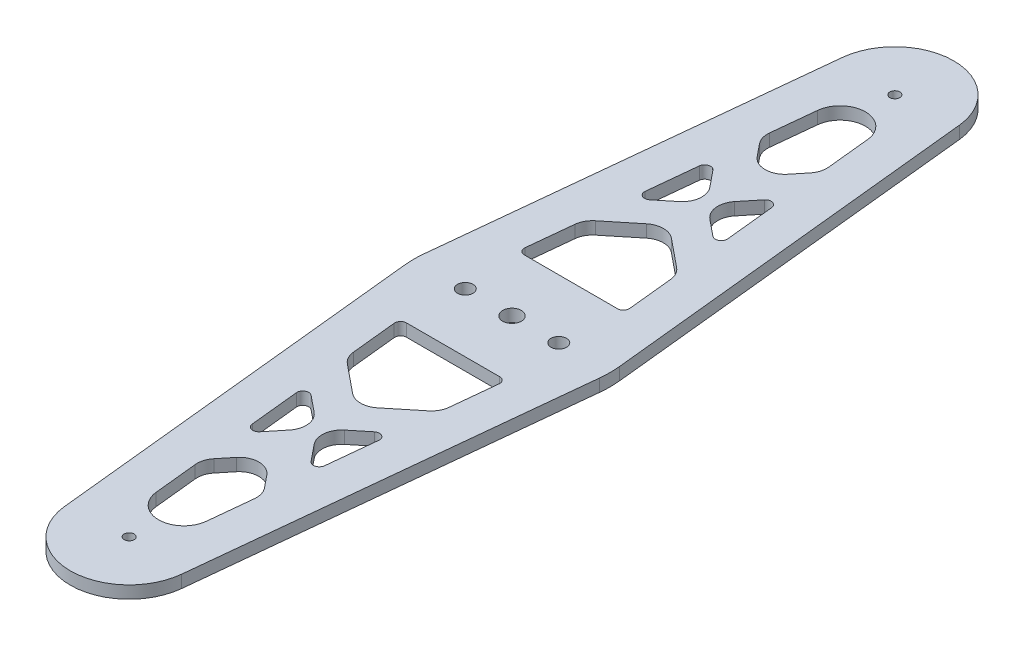
from build123d import *

# Parameters (mm, degrees)
BASE_DEPTH         = 6.35
SKETCH2_R          = 4.7752
SKETCH2_R_2        = 2.54
SKETCH2_R_3        = 3.96875
BOLTS_DEPTH        = 7.35
CUT_EXTRUDE1_DEPTH = 7.35


with BuildPart() as part:
    # Sketch1 → Base (new body)
    with BuildSketch(Plane(origin=(0, 0, 0), x_dir=(1, 0, 0), z_dir=(0, 1, 0))):
        with BuildLine():
            Line((-29.84179191, 198.076923077), (-49.736319849, 5.128205128))
            ThreePointArc((-49.736319849, 5.128205128), (-50, 0), (-49.736319849, -5.128205128))
            Line((-49.736319849, -5.128205128), (-29.84179191, -198.076923077))
            ThreePointArc((-29.84179191, -198.076923077), (0, -225), (29.84179191, -198.076923077))
            Line((29.84179191, -198.076923077), (49.736319849, -5.128205128))
            ThreePointArc((49.736319849, -5.128205128), (50, 0), (49.736319849, 5.128205128))
            Line((49.736319849, 5.128205128), (29.84179191, 198.076923077))
            ThreePointArc((29.84179191, 198.076923077), (0, 225), (-29.84179191, 198.076923077))
        make_face()
    extrude(amount=BASE_DEPTH)

    # Sketch2 → Bolts (cut, through all)
    with BuildSketch(Plane(origin=(0, 6.35, 0), x_dir=(1, 0, 0), z_dir=(0, 1, 0))):
        Circle(SKETCH2_R)
        with Locations((0, 195)):
            Circle(SKETCH2_R_2)
        with Locations((-23.8125, 0)):
            Circle(SKETCH2_R_3)
        with Locations((23.8125, 0)):
            Circle(SKETCH2_R_3)
        with Locations((0, -195)):
            Circle(SKETCH2_R_2)
    extrude(amount=-BOLTS_DEPTH, mode=Mode.SUBTRACT)

    # Sketch4 → Cut-Extrude1 (cut, through all)
    with BuildSketch(Plane(origin=(0, 6.35, 0), x_dir=(1, 0, 0), z_dir=(0, 1, 0))):
        with BuildLine():
            Line((-26.724762216, -33.307692308), (-24.340140182, -56.435145528))
            ThreePointArc((-24.340140182, -56.435145528), (-23.190453971, -60.163726372), (-20.701416296, -63.168520034))
            Line((-20.701416296, -63.168520034), (-6.308540083, -74.870782535))
            ThreePointArc((-6.308540083, -74.870782535), (0, -77.111767003), (6.308540083, -74.870782535))
            Line((6.308540083, -74.870782535), (20.701416296, -63.168520034))
            ThreePointArc((20.701416296, -63.168520034), (23.190453971, -60.163726372), (24.340140182, -56.435145528))
            Line((24.340140182, -56.435145528), (26.724762216, -33.307692308))
            ThreePointArc((26.724762216, -33.307692308), (25.968034139, -30.990407619), (23.740583026, -30))
            Line((23.740583026, -30), (-23.740583026, -30))
            ThreePointArc((-23.740583026, -30), (-25.968034139, -30.990407619), (-26.724762216, -33.307692308))
        make_face()
        with BuildLine():
            Line((16.120016428, -86.225819503), (7.759015532, -93.023809413))
            ThreePointArc((7.759015532, -93.023809413), (4.120291645, -99.757183919), (6.308540083, -107.091365027))
            Line((6.308540083, -107.091365027), (13.106529993, -115.452365924))
            ThreePointArc((13.106529993, -115.452365924), (16.291959962, -116.434574723), (18.418413843, -113.867496207))
            Line((18.418413843, -113.867496207), (20.996757644, -88.86121647))
            ThreePointArc((20.996757644, -88.86121647), (19.438845014, -85.914250835), (16.120016428, -86.225819503))
        make_face()
        with BuildLine():
            Line((-6.308540083, -107.091365027), (-13.106529993, -115.452365924))
            ThreePointArc((-13.106529993, -115.452365924), (-16.291959962, -116.434574723), (-18.418413843, -113.867496207))
            Line((-18.418413843, -113.867496207), (-20.996757644, -88.86121647))
            ThreePointArc((-20.996757644, -88.86121647), (-19.438845014, -85.914250835), (-16.120016428, -86.225819503))
            Line((-16.120016428, -86.225819503), (-7.759015532, -93.023809413))
            ThreePointArc((-7.759015532, -93.023809413), (-4.120291645, -99.757183919), (-6.308540083, -107.091365027))
        make_face()
        with BuildLine():
            Line((-7.759015532, -132.652629505), (-12.886782867, -138.95938604))
            ThreePointArc((-12.886782867, -138.95938604), (-14.710336749, -142.408841756), (-15.075031305, -146.293567149))
            Line((-15.075031305, -146.293567149), (-12.78933939, -168.461538462))
            ThreePointArc((-12.78933939, -168.461538462), (0, -180), (12.78933939, -168.461538462))
            Line((12.78933939, -168.461538462), (15.075031305, -146.293567149))
            ThreePointArc((15.075031305, -146.293567149), (14.710336749, -142.408841756), (12.886782867, -138.95938604))
            Line((12.886782867, -138.95938604), (7.759015532, -132.652629505))
            ThreePointArc((7.759015532, -132.652629505), (0, -128.961169588), (-7.759015532, -132.652629505))
        make_face()
        with BuildLine():
            Line((24.340140182, 56.435145528), (26.724762216, 33.307692308))
            ThreePointArc((26.724762216, 33.307692308), (25.968034139, 30.990407619), (23.740583026, 30))
            Line((23.740583026, 30), (-23.740583026, 30))
            ThreePointArc((-23.740583026, 30), (-25.968034139, 30.990407619), (-26.724762216, 33.307692308))
            Line((-26.724762216, 33.307692308), (-24.340140182, 56.435145528))
            ThreePointArc((-24.340140182, 56.435145528), (-23.190453971, 60.163726372), (-20.701416296, 63.168520034))
            Line((-20.701416296, 63.168520034), (-6.308540083, 74.870782535))
            ThreePointArc((-6.308540083, 74.870782535), (0, 77.111767003), (6.308540083, 74.870782535))
            Line((6.308540083, 74.870782535), (20.701416296, 63.168520034))
            ThreePointArc((20.701416296, 63.168520034), (23.190453971, 60.163726372), (24.340140182, 56.435145528))
        make_face()
        with BuildLine():
            Line((-16.120016428, 86.225819503), (-7.759015532, 93.023809413))
            ThreePointArc((-7.759015532, 93.023809413), (-4.120291645, 99.757183919), (-6.308540083, 107.091365027))
            Line((-6.308540083, 107.091365027), (-13.106529993, 115.452365924))
            ThreePointArc((-13.106529993, 115.452365924), (-16.291959962, 116.434574723), (-18.418413843, 113.867496207))
            Line((-18.418413843, 113.867496207), (-20.996757644, 88.86121647))
            ThreePointArc((-20.996757644, 88.86121647), (-19.438845014, 85.914250835), (-16.120016428, 86.225819503))
        make_face()
        with BuildLine():
            Line((6.308540083, 107.091365027), (13.106529993, 115.452365924))
            ThreePointArc((13.106529993, 115.452365924), (16.291959962, 116.434574723), (18.418413843, 113.867496207))
            Line((18.418413843, 113.867496207), (20.996757644, 88.86121647))
            ThreePointArc((20.996757644, 88.86121647), (19.438845014, 85.914250835), (16.120016428, 86.225819503))
            Line((16.120016428, 86.225819503), (7.759015532, 93.023809413))
            ThreePointArc((7.759015532, 93.023809413), (4.120291645, 99.757183919), (6.308540083, 107.091365027))
        make_face()
        with BuildLine():
            Line((12.78933939, 168.461538462), (15.075031305, 146.293567149))
            ThreePointArc((15.075031305, 146.293567149), (14.710336749, 142.408841756), (12.886782867, 138.95938604))
            Line((12.886782867, 138.95938604), (7.759015532, 132.652629505))
            ThreePointArc((7.759015532, 132.652629505), (0, 128.961169588), (-7.759015532, 132.652629505))
            Line((-7.759015532, 132.652629505), (-12.886782867, 138.95938604))
            ThreePointArc((-12.886782867, 138.95938604), (-14.710336749, 142.408841756), (-15.075031305, 146.293567149))
            Line((-15.075031305, 146.293567149), (-12.78933939, 168.461538462))
            ThreePointArc((-12.78933939, 168.461538462), (0, 180), (12.78933939, 168.461538462))
        make_face()
    extrude(amount=-CUT_EXTRUDE1_DEPTH, mode=Mode.SUBTRACT)


solid = part.part
